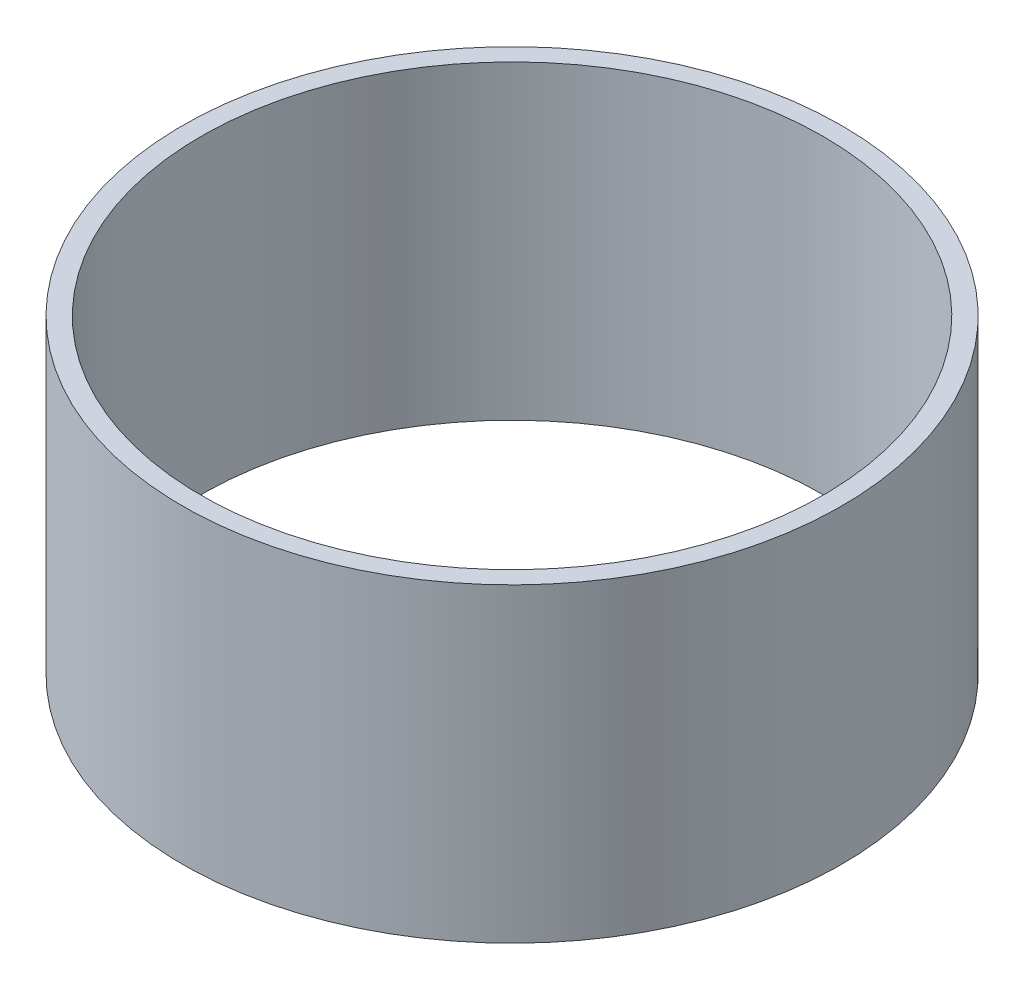
from build123d import *

# Parameters (mm, degrees)
SKETCH1_W = 1.524
SKETCH1_H = 25.4


with BuildPart() as part:
    # Sketch1 → Revolve1 (revolve)
    with BuildSketch(Plane.XY):
        with Locations((26.2128, 12.7)):
            Rectangle(SKETCH1_W, SKETCH1_H)
    revolve(axis=Axis((0, -13.97, 0), (0, 1, 0)))


solid = part.part
